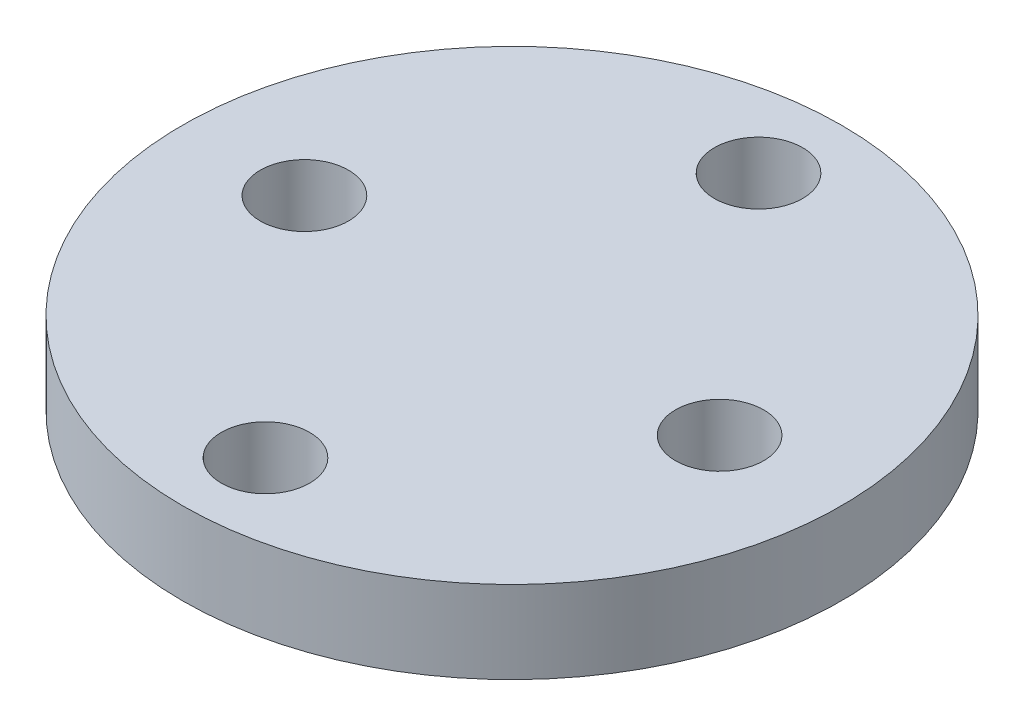
from build123d import *

# Parameters (mm, degrees)
SKETCH1_R           = 12.7
SKETCH1_R_2         = 1.7
BOSS_EXTRUDE1_DEPTH = 3.175


with BuildPart() as part:
    # Sketch1 → Boss-Extrude1 (new body)
    with BuildSketch(Plane(origin=(0, 0, 0), x_dir=(1, 0, 0), z_dir=(0, 1, 0))):
        Circle(SKETCH1_R)
        with Locations((0, 9.5)):
            Circle(SKETCH1_R_2, mode=Mode.SUBTRACT)
        with Locations((0, -9.5)):
            Circle(SKETCH1_R_2, mode=Mode.SUBTRACT)
        with Locations((-8, 0)):
            Circle(SKETCH1_R_2, mode=Mode.SUBTRACT)
        with Locations((8, 0)):
            Circle(SKETCH1_R_2, mode=Mode.SUBTRACT)
    extrude(amount=BOSS_EXTRUDE1_DEPTH)


solid = part.part
